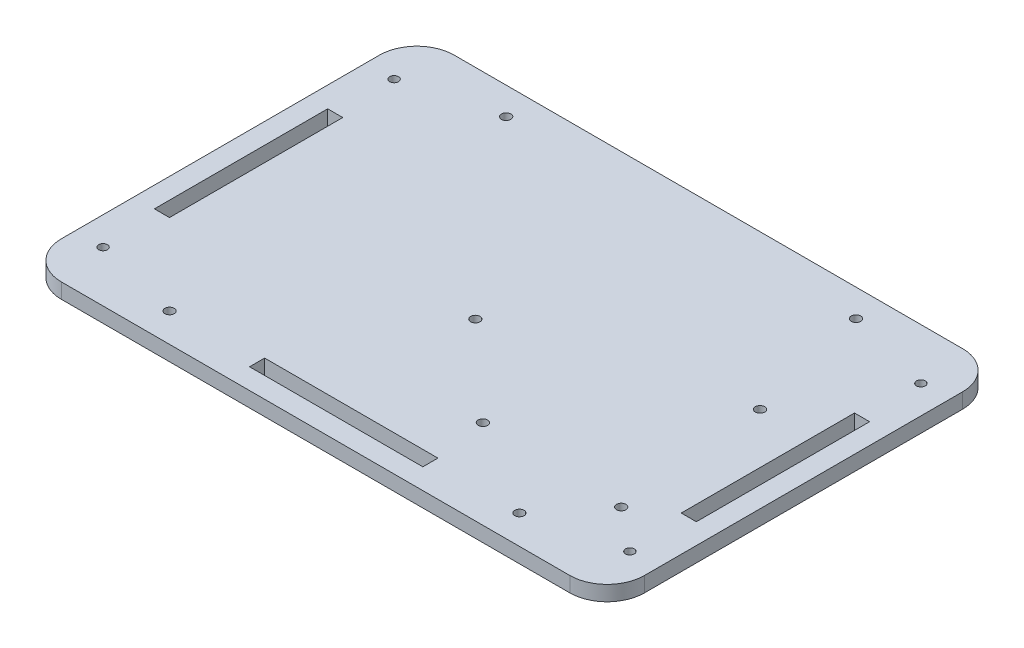
from build123d import *

# Parameters (mm, degrees)
MAIN_DEPTH               = 5.13
SKETCH2_R                = 1.5
SKETCH2_W                = 5.13
SKETCH2_H                = 58.88
CUT_EXTRUDE1_DEPTH       = 5.13
TOOTH_SLOT_REACH         = 7.13
SKETCH3_W                = 58.88
SKETCH3_H                = 5.13
LPATTERN1_COUNT          = 2
LPATTERN1_PITCH          = 118.88
LPATTERN1_COUNT_DIR2     = 2
LPATTERN1_PITCH_DIR2     = 114.36
M3_CLEARANCE_HOLE4_D     = 3.2
M3_CLEARANCE_HOLE4_DEPTH = 5.1
M3_CLEARANCE_HOLE4_TIP   = 0.96137699


with BuildPart() as part:
    # Sketch1 → Main (new body)
    with BuildSketch(Plane(origin=(0, 0, 0), x_dir=(1, 0, 0), z_dir=(0, 1, 0))):
        with BuildLine():
            Line((-55.207201859, 101.249932113), (117.542798141, 101.249932113))
            ThreePointArc((117.542798141, 101.249932113), (126.523054262, 97.530188234), (130.242798141, 88.549932113))
            Line((130.242798141, 88.549932113), (130.242798141, -19.530067887))
            ThreePointArc((130.242798141, -19.530067887), (126.523054262, -28.510324008), (117.542798141, -32.230067887))
            Line((117.542798141, -32.230067887), (-55.207201859, -32.230067887))
            ThreePointArc((-55.207201859, -32.230067887), (-64.18745798, -28.510324008), (-67.907201859, -19.530067887))
            Line((-67.907201859, -19.530067887), (-67.907201859, 88.549932113))
            ThreePointArc((-67.907201859, 88.549932113), (-64.18745798, 97.530188234), (-55.207201859, 101.249932113))
        make_face()
    extrude(amount=MAIN_DEPTH)

    # Sketch2 → Cut-Extrude1 (cut)
    with BuildSketch(Plane(origin=(0, 5.13, 0), x_dir=(1, 0, 0), z_dir=(0, 1, 0))):
        with Locations((-58.347201859, -14.930067887)):
            Circle(SKETCH2_R)
        with Locations((-58.347201859, 83.949932113)):
            Circle(SKETCH2_R)
        with Locations((120.682798141, 83.949932113)):
            Circle(SKETCH2_R)
        with Locations((120.682798141, -14.930067887)):
            Circle(SKETCH2_R)
        with Locations((-58.342201859, 34.509932113)):
            Rectangle(SKETCH2_W, SKETCH2_H)
        with Locations((120.677798141, 34.509932113)):
            Rectangle(SKETCH2_W, SKETCH2_H)
    extrude(amount=-CUT_EXTRUDE1_DEPTH, mode=Mode.SUBTRACT)

    # Sketch3 → tooth slot (cut, up to next)
    with BuildSketch(Plane(origin=(0, 5.13, 0), x_dir=(1, 0, 0), z_dir=(0, 1, 0)), mode=Mode.PRIVATE) as tooth_slot_sk1:
        with Locations((31.167798141, -22.665067887)):
            Rectangle(SKETCH3_W, SKETCH3_H)
    tooth_slot_tool1 = extrude(tooth_slot_sk1.sketch, amount=-TOOTH_SLOT_REACH, mode=Mode.PRIVATE) & part.part
    add(tooth_slot_tool1.solids().sort_by_distance((31.167798, 5.13, 22.665068))[0], mode=Mode.SUBTRACT)

    # Sketch4 → M3 Clearance Hole1 (revolve, cut)
    with BuildSketch(Plane(origin=(-28.272201859, 5.13, 22.401258672), x_dir=(0, 0, 1), z_dir=(1, 0, 0))):
        Polygon((0, 0), (0, 6.06137699), (1.6, 5.1), (1.6, 0), align=None)
    m3_clearance_hole1 = revolve(axis=Axis((-28.272201859, 11.48, 22.401258672), (0, -1, 0)), mode=Mode.SUBTRACT)

    # LPattern1: M3 Clearance Hole1 2 × 2
    with Locations(*[(i * LPATTERN1_PITCH, 0, -j * LPATTERN1_PITCH_DIR2) for i in range(LPATTERN1_COUNT) for j in range(LPATTERN1_COUNT_DIR2) if (i, j) != (0, 0)]):
        add(m3_clearance_hole1, mode=Mode.SUBTRACT)

    # M3 Clearance Hole4
    with Locations(Plane(origin=(0, 5.13, 0), x_dir=(-1, 0, 0), z_dir=(0, 1, 0))):
        with Locations((-100.998782657, -48.960031461), (-106.146516037, 3.363968539), (-57.818782657, 2.039968539), (-26.068782657, -27.170031461)):
            Hole(M3_CLEARANCE_HOLE4_D / 2, depth=M3_CLEARANCE_HOLE4_DEPTH)
            with Locations((0, 0, -(M3_CLEARANCE_HOLE4_DEPTH + M3_CLEARANCE_HOLE4_TIP / 2))):  # 118° drill point
                Cone(0, M3_CLEARANCE_HOLE4_D / 2, M3_CLEARANCE_HOLE4_TIP, mode=Mode.SUBTRACT)


solid = part.part
